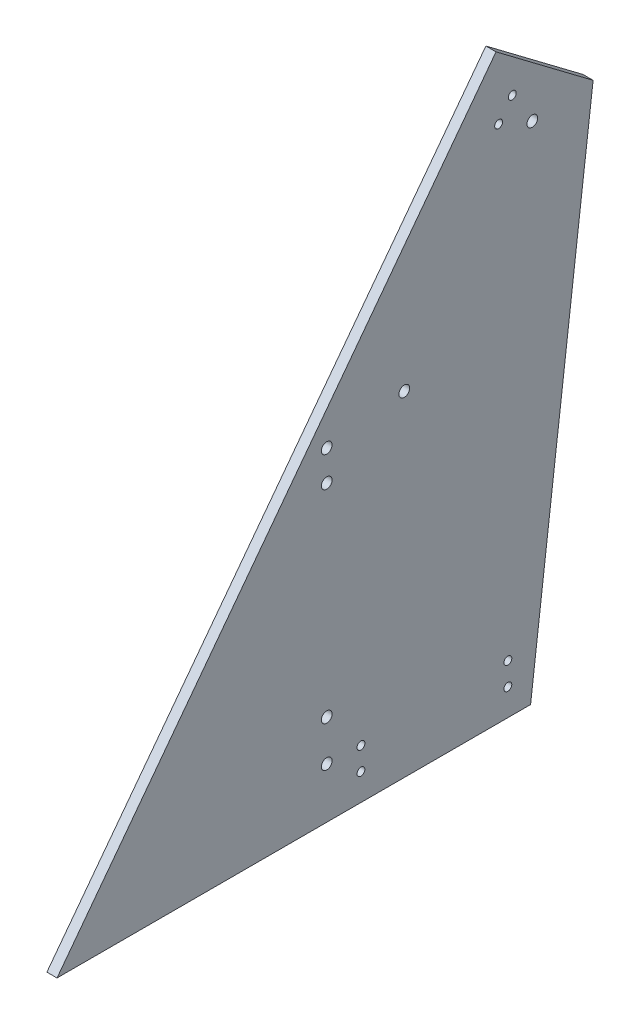
from build123d import *

# Parameters (mm, degrees)
BOSS_EXTRUDE1_DEPTH = 6.35
SKETCH2_R           = 3.3655
CUT_EXTRUDE1_DEPTH  = 7.35
SKETCH3_R           = 2.4638
CUT_EXTRUDE2_DEPTH  = 7.35
SKETCH4_R           = 3.3655
CUT_EXTRUDE3_DEPTH  = 7.35


with BuildPart() as part:
    # Sketch1 → Boss-Extrude1 (new body)
    with BuildSketch(Plane(origin=(0, 0, 0), x_dir=(0, 0, -1), z_dir=(1, 0, 0))):
        Polygon((0, 0), (275.149828585, 365.136155194), (336.005854451, 319.277850429), (296.80346378, 0), align=None)
    extrude(amount=BOSS_EXTRUDE1_DEPTH)

    # Sketch2 → Cut-Extrude1 (cut, through all)
    with BuildSketch(Plane(origin=(6.35, 0, 0), x_dir=(0, 0, -1), z_dir=(1, 0, 0))):
        with Locations((169.042319417, 203.2)):
            Circle(SKETCH2_R)
        with Locations((169.042319417, 184.15)):
            Circle(SKETCH2_R)
        with Locations((169.042319417, 57.15)):
            Circle(SKETCH2_R)
        with Locations((169.042319417, 31.75)):
            Circle(SKETCH2_R)
    extrude(amount=-CUT_EXTRUDE1_DEPTH, mode=Mode.SUBTRACT)

    # Sketch3 → Cut-Extrude2 (cut, through all)
    with BuildSketch(Plane(origin=(6.35, 0, 0), x_dir=(0, 0, -1), z_dir=(1, 0, 0))):
        with Locations((190.5, 30.988)):
            Circle(SKETCH3_R)
        with Locations((190.5, 16.764)):
            Circle(SKETCH3_R)
        with Locations((282.575, 30.988)):
            Circle(SKETCH3_R)
        with Locations((282.575, 16.764)):
            Circle(SKETCH3_R)
        with Locations((285.346343492, 336.461727915)):
            Circle(SKETCH3_R)
        with Locations((276.786126603, 325.10193642)):
            Circle(SKETCH3_R)
    extrude(amount=-CUT_EXTRUDE2_DEPTH, mode=Mode.SUBTRACT)

    # Sketch4 → Cut-Extrude3 (cut, through all)
    with BuildSketch(Plane(origin=(6.35, 0, 0), x_dir=(0, 0, -1), z_dir=(1, 0, 0))):
        with Locations((297.898743163, 316.189372761)):
            Circle(SKETCH4_R)
        with Locations((217.646709826, 209.691327496)):
            Circle(SKETCH4_R)
    extrude(amount=-CUT_EXTRUDE3_DEPTH, mode=Mode.SUBTRACT)


solid = part.part
